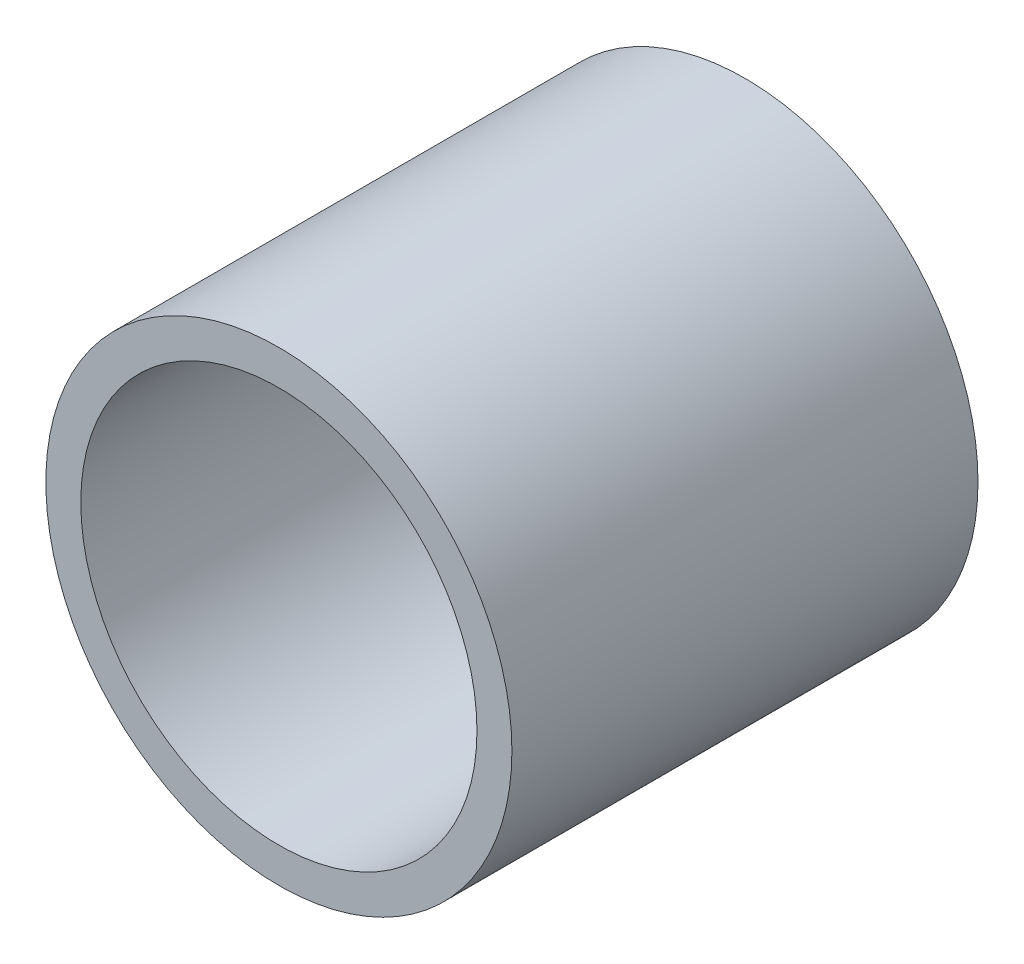
from build123d import *

# Parameters (mm, degrees)
ESQUISSE1_R        = 40
ESQUISSE1_R_2      = 34
EXTRU_MINCE1_DEPTH = 80


with BuildPart() as part:
    # Esquisse1 → Extru.-Mince1 (new body)
    with BuildSketch(Plane.XY):
        Circle(ESQUISSE1_R)
        Circle(ESQUISSE1_R_2, mode=Mode.SUBTRACT)
    extrude(amount=EXTRU_MINCE1_DEPTH)


solid = part.part
